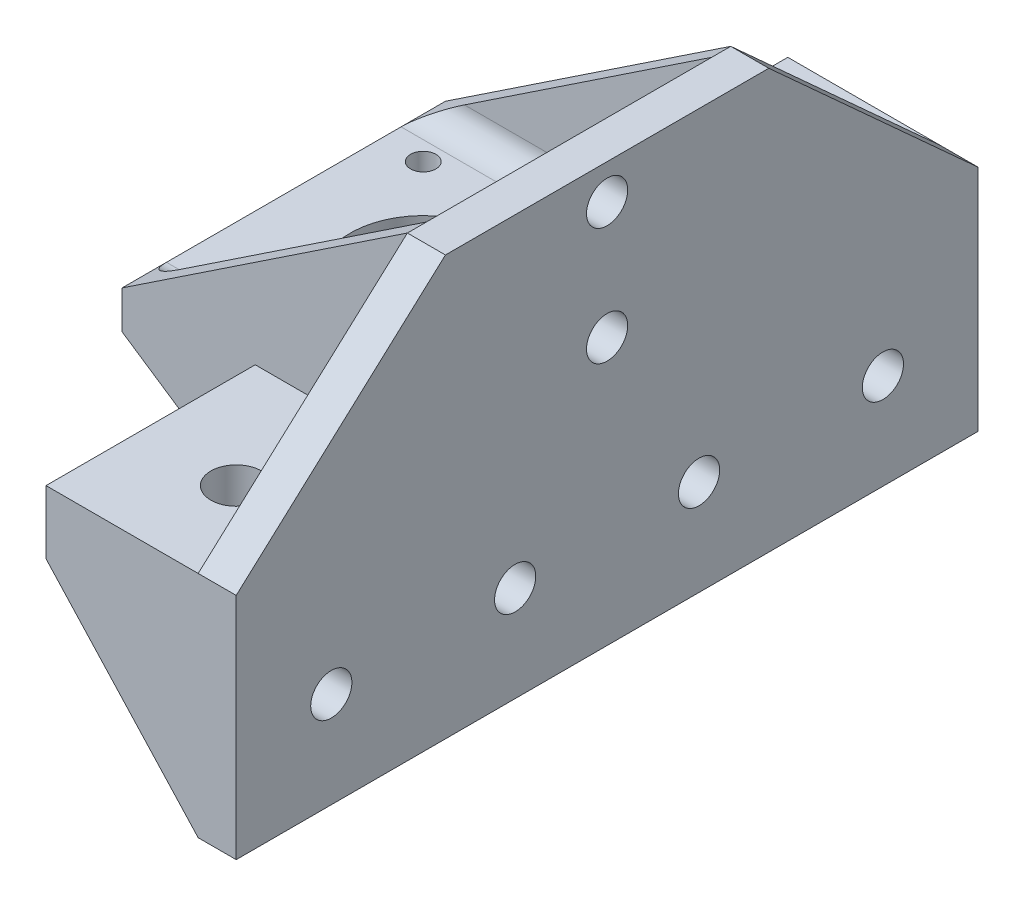
from build123d import *
from OCP.BRepFilletAPI import BRepFilletAPI_MakeFillet

# Parameters (mm, degrees)
SKETCH2_W                  = 45
SKETCH2_H                  = 45
BOSS_EXTRUDE1_DEPTH        = 6
SKETCH4_R                  = 11.5
SKETCH4_R_2                = 2
CUT_EXTRUDE1_DEPTH         = 64.921827258
SKETCH5_W                  = 6
SKETCH5_H                  = 45
BOSS_EXTRUDE2_DEPTH        = 30.1
BOSS_EXTRUDE2_DEPTH_BACK   = 36
BOSS_EXTRUDE3_DEPTH        = 3
BOSS_EXTRUDE4_DEPTH        = 3
BOSS_EXTRUDE5_DEPTH        = 28
BOSS_EXTRUDE6_DEPTH        = 5
FILLET3_R                  = 10
FILLET4_R1                 = 4
FILLET4_R2                 = 2
FILLET4_R3                 = 1.2
FILLET4_R4                 = 1.5
BOSS_EXTRUDE7_DEPTH        = 28
BOSS_EXTRUDE8_DEPTH        = 5
FILLET5_R                  = 10
F_6_5_6_5_DIAMETER_HOLE1_D = 6.5
SKETCH14_R                 = 4
CUT_EXTRUDE2_DEPTH         = 7.5
BOSS_EXTRUDE9_DEPTH        = 6


with BuildPart() as part:
    # Sketch2 → Boss-Extrude1 (new body)
    with BuildSketch(Plane(origin=(0, 0, 0), x_dir=(1, 0, 0), z_dir=(0, 1, 0))):
        with Locations((22.5, 22.5)):
            Rectangle(SKETCH2_W, SKETCH2_H)
    extrude(amount=BOSS_EXTRUDE1_DEPTH)

    # Sketch4 → Cut-Extrude1 (cut, through all)
    with BuildSketch(Plane(origin=(0, 6, 0), x_dir=(-1, 0, 0), z_dir=(0, 1, 0))):
        with Locations(Location((-22, -22.5, 0), (0, 0, 90))):
            Circle(SKETCH4_R)
        with Locations(Location((-37.5, -7, 0), (0, 0, 90))):
            Circle(SKETCH4_R_2)
        with Locations(Location((-6.5, -7, 0), (0, 0, 90))):
            Circle(SKETCH4_R_2)
        with Locations(Location((-6.5, -38, 0), (0, 0, 90))):
            Circle(SKETCH4_R_2)
        with Locations(Location((-37.5, -38, 0), (0, 0, 90))):
            Circle(SKETCH4_R_2)
    extrude(amount=-CUT_EXTRUDE1_DEPTH, mode=Mode.SUBTRACT)

    # Sketch5 → Boss-Extrude2 (add, two sides)
    with BuildSketch(Plane.XZ) as boss_extrude2_sk:
        with Locations((48, -22.5)):
            Rectangle(SKETCH5_W, SKETCH5_H)
    extrude(amount=BOSS_EXTRUDE2_DEPTH)
    extrude(boss_extrude2_sk.sketch, amount=-BOSS_EXTRUDE2_DEPTH_BACK)

    # Sketch8 → Boss-Extrude3 (add)
    with BuildSketch(Plane.XY):
        Polygon((45, 36), (0, 6), (0, 0), (45, -30.1), (51, -30.1), (51, 36), align=None)
    extrude(amount=BOSS_EXTRUDE3_DEPTH)

    # Sketch9 → Boss-Extrude4 (add)
    with BuildSketch(Plane(origin=(0, 0, -45), x_dir=(-1, 0, 0), z_dir=(0, 0, -1))):
        Polygon((0, 6), (-45, 36), (-51, 36), (-51, -30.1), (-45, -30.1), (0, 0), align=None)
    extrude(amount=BOSS_EXTRUDE4_DEPTH)

    # Sketch11 → Boss-Extrude5 (add)
    with BuildSketch(Plane.XY.offset(3)):
        Polygon((51, -30.1), (45, -30.1), (45, -4), (21, -4), (21, 6), (51, 6), align=None)
    extrude(amount=BOSS_EXTRUDE5_DEPTH)

    # Sketch12 → Boss-Extrude6 (add)
    with BuildSketch(Plane.XY.offset(31)):
        Polygon((45, -30.1), (21, -4), (21, 6), (51, 6), (51, -30.1), align=None)
    extrude(amount=BOSS_EXTRUDE6_DEPTH)

    # Fillet3
    fillet3_edges = [part.edges().sort_by_distance(p)[0] for p in [
        (33, -4, 3),
        (33, -4, 31),
    ]]
    fillet(fillet3_edges, radius=FILLET3_R)

    # Fillet4: one fillet with a radius per group of edges: ONE call of the kernel's fillet builder (fillet() takes one radius for all edges)
    fillet4_edges_1 = [part.edges().sort_by_distance(p)[0] for p in [
        (22.5, 6, -45),
        (22.5, 6, 0),
    ]]
    fillet4_edges_2 = [part.edges().sort_by_distance(p)[0] for p in [
        (45, 6, -22.5),
    ]]
    fillet4_edges_3 = [part.edges().sort_by_distance(p)[0] for p in [
        (22.5, 0, -45),
        (22.5, 0, 0),
    ]]
    fillet4_edges_4 = [part.edges().sort_by_distance(p)[0] for p in [
        (45, 0, -22.5),
    ]]
    fillet4 = BRepFilletAPI_MakeFillet(part.part.solid().wrapped)
    for e in fillet4_edges_1:
        fillet4.Add(FILLET4_R1, e.wrapped)
    for e in fillet4_edges_2:
        fillet4.Add(FILLET4_R2, e.wrapped)
    for e in fillet4_edges_3:
        fillet4.Add(FILLET4_R3, e.wrapped)
    for e in fillet4_edges_4:
        fillet4.Add(FILLET4_R4, e.wrapped)
    add(Compound.cast(fillet4.Shape()), mode=Mode.REPLACE)

    # Sketch15 → Boss-Extrude7 (add)
    with BuildSketch(Plane(origin=(0, 0, -48), x_dir=(-1, 0, 0), z_dir=(0, 0, -1))):
        Polygon((-51, -30.1), (-51, 6), (-21, 6), (-21, -4), (-45, -4), (-45, -30.1), align=None)
    extrude(amount=BOSS_EXTRUDE7_DEPTH)

    # Sketch16 → Boss-Extrude8 (add)
    with BuildSketch(Plane(origin=(0, 0, -76), x_dir=(-1, 0, 0), z_dir=(0, 0, -1))):
        Polygon((-45, -30.1), (-21, -4), (-21, 6), (-51, 6), (-51, -30.1), align=None)
    extrude(amount=BOSS_EXTRUDE8_DEPTH)

    # Fillet5
    fillet5_edges = [part.edges().sort_by_distance(p)[0] for p in [
        (33, -4, -48),
        (33, -4, -76),
    ]]
    fillet(fillet5_edges, radius=FILLET5_R)

    # 6.5 _6.5_ Diameter Hole1 (through all)
    with Locations(Plane.ZY.offset(-45)):
        with Locations((-22.5, 12), (-22.5, 30.5), (-37, -15), (-8, -15), (21, -15), (-66, -15)):
            Hole(F_6_5_6_5_DIAMETER_HOLE1_D / 2)

    # Sketch14 → Cut-Extrude2 (cut)
    with BuildSketch(Plane(origin=(0, 6, 0), x_dir=(1, 0, 0), z_dir=(0, 1, 0))):
        with Locations(Location((36, -21, 0), (0, 0, 180))):
            Circle(SKETCH14_R)
        with Locations(Location((36, 66, 0), (0, 0, 180))):
            Circle(SKETCH14_R)
    extrude(amount=-CUT_EXTRUDE2_DEPTH, mode=Mode.SUBTRACT)

    # Sketch17 → Boss-Extrude9 (add)
    with BuildSketch(Plane(origin=(51, 0, 0), x_dir=(0, 0, -1), z_dir=(1, 0, 0))):
        Polygon((-3, 36), (-36, 6), (-3, 6), align=None)
        Polygon((48, 36), (81, 6), (48, 6), align=None)
    extrude(amount=-BOSS_EXTRUDE9_DEPTH)


solid = part.part
